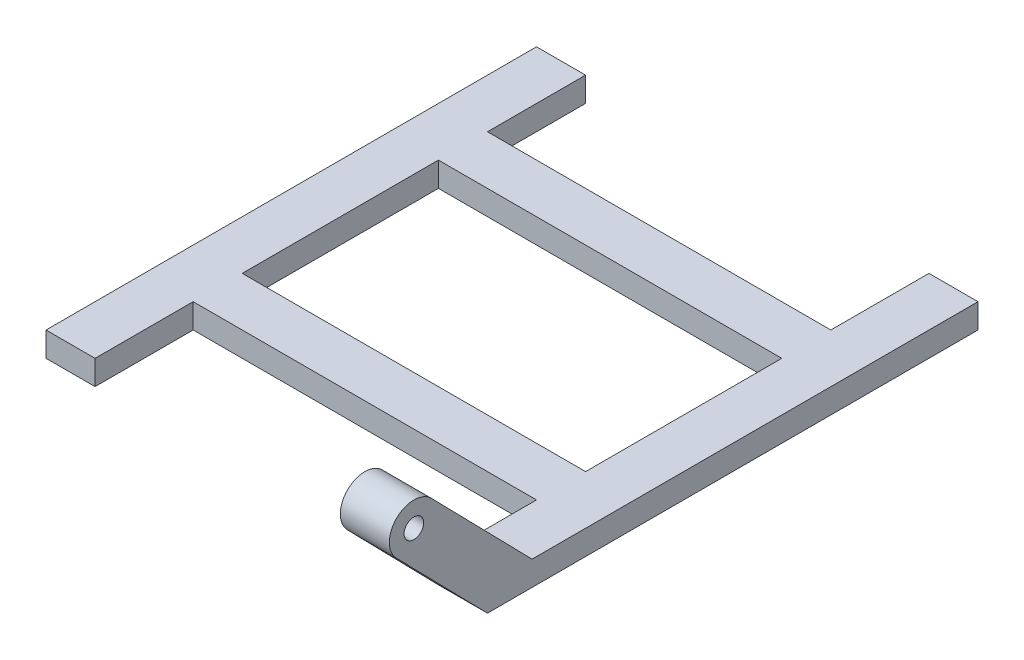
from build123d import *

# Parameters (mm, degrees)
ESQUISSE1_W        = 70
ESQUISSE1_H        = 10
BOSS_EXTRU_1_DEPTH = 5
ESQUISSE3_R        = 5
ESQUISSE3_R_2      = 2
BOSS_EXTRU_2_DEPTH = 10


with BuildPart() as part:
    # Esquisse1 → Boss.-Extru.1 (new body)
    with BuildSketch(Plane(origin=(0, 0, 0), x_dir=(1, 0, 0), z_dir=(0, 1, 0))):
        Polygon((-35, -45), (-35, -5), (-35, 5), (-35, 25), (-45, 25), (-45, -75), (-35, -75), (-35, -55), align=None)
        Rectangle(ESQUISSE1_W, ESQUISSE1_H)
        Polygon((35, 5), (35, -5), (35, -45), (35, -55), (35, -75), (45, -75), (45, 25), (35, 25), align=None)
        with Locations((0, -50)):
            Rectangle(ESQUISSE1_W, ESQUISSE1_H)
    extrude(amount=BOSS_EXTRU_1_DEPTH)

    # Esquisse3 → Boss.-Extru.2 (add)
    with BuildSketch(Plane(origin=(45, 0, 0), x_dir=(0, 0, -1), z_dir=(1, 0, 0))):
        with BuildLine():
            Line((-93.575697107, 19.005090817), (-75, 0))
            Line((-75, 0), (-75, 5))
            Line((-75, 5), (-65.90374461, 5))
            Line((-65.90374461, 5), (-86.424302893, 25.994909183))
            ThreePointArc((-86.424302893, 25.994909183), (-85.369747008, 24.386996882), (-85, 22.5))
            ThreePointArc((-85, 22.5), (-88.113003118, 17.869747008), (-93.575697107, 19.005090817))
        make_face()
        with Locations((-90, 22.5)):
            Circle(ESQUISSE3_R)
        with Locations((-90, 22.5)):
            Circle(ESQUISSE3_R_2, mode=Mode.SUBTRACT)
    extrude(amount=-BOSS_EXTRU_2_DEPTH)


solid = part.part
